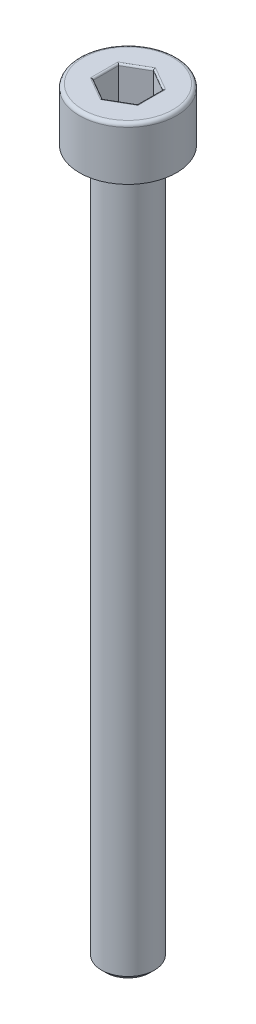
from build123d import *

# Parameters (mm, degrees)
CHAMFER1_SIZE      = 0.25
FILLET1_R          = 0.2
CUT_EXTRUDE1_DEPTH = 2
FILLET2_R          = 0.1


with BuildPart() as part:
    # Sketch1 → Revolve1 (revolve)
    with BuildSketch(Plane.XY):
        Polygon((0, -43), (-1.5, -43), (-1.5, -3), (-2.75, -3), (-2.75, 0), (0, 0), align=None)
    revolve(axis=Axis((0, 0, 0), (0, -1, 0)))

    # Chamfer1
    chamfer1_edges = [part.edges().sort_by_distance(p)[0] for p in [
        (1.5, -3, 0),
        (1.5, -43, 0),
    ]]
    chamfer(chamfer1_edges, length=CHAMFER1_SIZE)

    # Fillet1
    fillet1_edges = [part.edges().sort_by_distance(p)[0] for p in [
        (2.75, 0, 0),
    ]]
    fillet(fillet1_edges, radius=FILLET1_R)

    # Sketch2 → Cut-Extrude1 (cut)
    with BuildSketch(Plane(origin=(0, 0, 0), x_dir=(1, 0, 0), z_dir=(0, 1, 0))):
        Polygon((0, 1.443375673), (-1.25, 0.721687836), (-1.25, -0.721687836), (0, -1.443375673), (1.25, -0.721687836), (1.25, 0.721687836), align=None)
    extrude(amount=-CUT_EXTRUDE1_DEPTH, mode=Mode.SUBTRACT)

    # Fillet2
    fillet2_edges = [part.edges().sort_by_distance(p)[0] for p in [
        (0.625, -2, -1.082531755),
        (1.25, -2, 0),
        (0.625, -2, 1.082531755),
        (-0.625, -2, 1.082531755),
        (-1.25, -2, 0),
        (-0.625, -2, -1.082531755),
        (0.625, 0, -1.082531755),
        (-0.625, 0, -1.082531755),
        (-1.25, 0, 0),
        (-0.625, 0, 1.082531755),
        (0.625, 0, 1.082531755),
        (1.25, 0, 0),
    ]]
    fillet(fillet2_edges, radius=FILLET2_R)


solid = part.part
